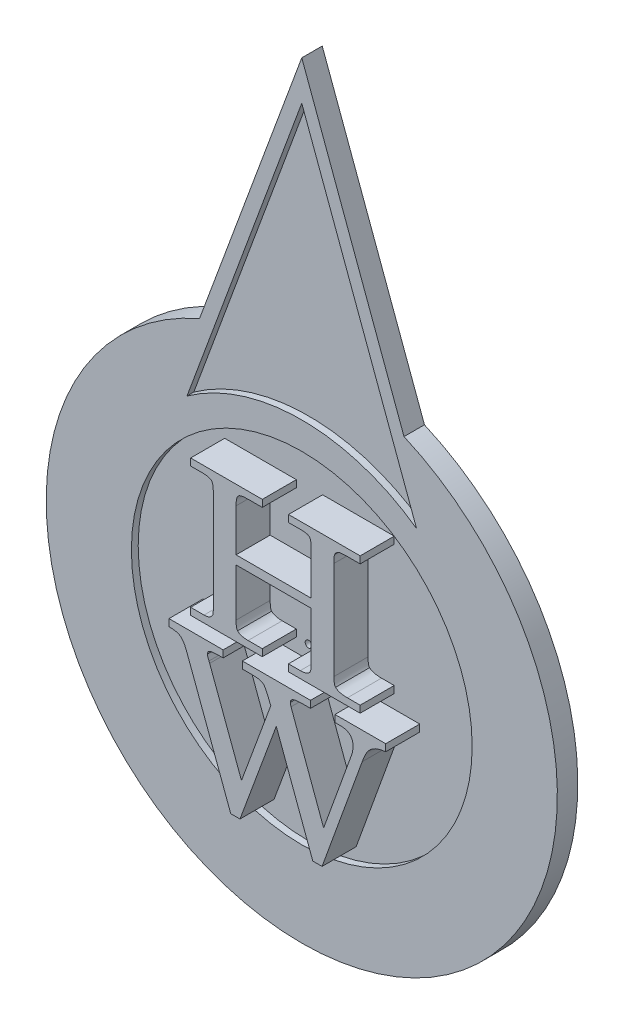
from build123d import *

# Parameters (mm, degrees)
BOSS_EXTRUDE1_DEPTH   = 3
SKETCH2_R             = 25
CUT_EXTRUDE1_DEPTH    = 1
SKETCH3_R             = 0.5
CUT_EXTRUDE2_DEPTH    = 3
CUT_EXTRUDE3_DEPTH    = 1
BOSS_EXTRUDE2_DEPTH   = 5
BOSS_EXTRUDE2_2_DEPTH = 5


with BuildPart() as part:
    # Sketch1 → Boss-Extrude1 (new body)
    with BuildSketch(Plane.XY):
        with BuildLine():
            Line((0, 75), (15, 34.369317712))
            ThreePointArc((15, 34.369317712), (0, -37.5), (-15, 34.369317712))
            Line((-15, 34.369317712), (0, 75))
        make_face()
    extrude(amount=BOSS_EXTRUDE1_DEPTH)

    # Sketch2 → Cut-Extrude1 (cut)
    with BuildSketch(Plane.XY.offset(3)):
        Circle(SKETCH2_R)
    extrude(amount=-CUT_EXTRUDE1_DEPTH, mode=Mode.SUBTRACT)

    # Sketch3 → Cut-Extrude2 (cut, through all)
    with BuildSketch(Plane.XY.offset(2)):
        Circle(SKETCH3_R)
    extrude(amount=-CUT_EXTRUDE2_DEPTH, mode=Mode.SUBTRACT)

    # Sketch4 → Cut-Extrude3 (cut)
    with BuildSketch(Plane.XY.offset(3)):
        with BuildLine():
            Line((16.840424663, 23.609322252), (0, 69.225185189))
            Line((0, 69.225185189), (-16.840424663, 23.609322252))
            ThreePointArc((-16.840424663, 23.609322252), (0, 29), (16.840424663, 23.609322252))
        make_face()
    extrude(amount=-CUT_EXTRUDE3_DEPTH, mode=Mode.SUBTRACT)


with BuildPart() as body_2:
    # Sketch5 → Boss-Extrude2 (new body)
    with BuildSketch(Plane.XY.offset(2)):
        with BuildLine():
            Line((-12.307692308, 20), (-1.794871795, 20))
            Line((-1.794871795, 20), (-1.794871795, 18.974358974))
            Line((-1.794871795, 18.974358974), (-3.878205128, 18.974358974))
            add(Edge.make_bspline(
                [(-3.878205128, 18.974358974), (-4.045156685, 18.970238719), (-4.348009251, 18.962764516), (-4.75953362, 18.918280987), (-5.074389701, 18.825957021), (-5.322099839, 18.693709511), (-5.475784154, 18.460687387), (-5.574066192, 18.146925306), (-5.633474469, 17.733149921), (-5.638341942, 17.422745299), (-5.641025641, 17.251602564)],
                knots=[0, 0, 0, 0, 0.000501202, 0.000909187, 0.001236146, 0.001484188, 0.001731029, 0.002049053, 0.002466663, 0.002979874, 0.002979874, 0.002979874, 0.002979874], degree=3))
            Line((-5.641025641, 17.251602564), (-5.641025641, 11.025641026))
            Line((-5.641025641, 11.025641026), (5.384615385, 11.025641026))
            Line((5.384615385, 11.025641026), (5.384615385, 17.251602564))
            add(Edge.make_bspline(
                [(5.384615385, 17.251602564), (5.383740839, 17.345077966), (5.38207839, 17.522767966), (5.372601025, 17.775774388), (5.345529534, 17.999673297), (5.322373184, 18.196376391), (5.279476869, 18.362860867), (5.236415565, 18.504296733), (5.173075514, 18.613578951), (5.084965049, 18.737881846), (4.896619502, 18.841281892), (4.607469436, 18.919925385), (4.225496381, 18.968656993), (3.939741887, 18.97233133), (3.782051282, 18.974358974)],
                knots=[0, 0, 0, 0, 0.000280477, 0.000533167, 0.00075881, 0.000957117, 0.001126196, 0.001274433, 0.001398178, 0.001503951, 0.001727342, 0.002020139, 0.002404295, 0.002877323, 0.002877323, 0.002877323, 0.002877323], degree=3))
            Line((3.782051282, 18.974358974), (2.051282051, 18.974358974))
            Line((2.051282051, 18.974358974), (2.051282051, 20))
            Line((2.051282051, 20), (12.564102564, 20))
            Line((12.564102564, 20), (12.564102564, 18.974358974))
            Line((12.564102564, 18.974358974), (10.456730769, 18.974358974))
            add(Edge.make_bspline(
                [(10.456730769, 18.974358974), (10.33515654, 18.973412428), (10.111642638, 18.971672205), (9.804429896, 18.945190942), (9.555917373, 18.89911702), (9.354816273, 18.836103073), (9.195676394, 18.740158358), (9.051486735, 18.628075987), (8.928149378, 18.481720833), (8.860689946, 18.370363816), (8.826121795, 18.313301282)],
                knots=[0, 0, 0, 0, 0.000364671, 0.000670447, 0.000923455, 0.001122368, 0.001298285, 0.00147786, 0.001668196, 0.001868236, 0.001868236, 0.001868236, 0.001868236], degree=3))
            add(Edge.make_bspline(
                [(8.826121795, 18.313301282), (8.808341001, 18.260272466), (8.76352112, 18.126603227), (8.742750032, 17.868690487), (8.721346843, 17.521873823), (8.719165775, 17.258399472), (8.717948718, 17.111378205)],
                knots=[0, 0, 0, 0, 0.000167313, 0.000421743, 0.000770876, 0.001211654, 0.001211654, 0.001211654, 0.001211654], degree=3))
            Line((8.717948718, 17.111378205), (8.717948718, 2.740384615))
            add(Edge.make_bspline(
                [(8.717948718, 2.740384615), (8.720199802, 2.583711901), (8.724213445, 2.304367259), (8.768525981, 1.940093321), (8.823772727, 1.66299249), (8.916083263, 1.538114394), (8.954326923, 1.486378205)],
                knots=[0, 0, 0, 0, 0.000469024, 0.000836261, 0.001106479, 0.001297614, 0.001297614, 0.001297614, 0.001297614], degree=3))
            add(Edge.make_bspline(
                [(8.954326923, 1.486378205), (9.047471267, 1.414271371), (9.249560154, 1.257826122), (9.652311829, 1.124236043), (10.14146426, 1.036373311), (10.501559145, 1.029418154), (10.697115385, 1.025641026)],
                knots=[0, 0, 0, 0, 0.000351196, 0.000761965, 0.001254688, 0.001840296, 0.001840296, 0.001840296, 0.001840296], degree=3))
            Line((10.697115385, 1.025641026), (12.564102564, 1.025641026))
            Line((12.564102564, 1.025641026), (12.564102564, 0))
            Line((12.564102564, 0), (2.051282051, 0))
            Line((2.051282051, 0), (2.051282051, 1.025641026))
            Line((2.051282051, 1.025641026), (3.782051282, 1.025641026))
            add(Edge.make_bspline(
                [(3.782051282, 1.025641026), (3.940285465, 1.029508782), (4.231662998, 1.036630994), (4.628207098, 1.124180298), (4.953900622, 1.265674046), (5.105185316, 1.421268776), (5.176282051, 1.494391026)],
                knots=[0, 0, 0, 0, 0.000473588, 0.000872079, 0.00121434, 0.001517798, 0.001517798, 0.001517798, 0.001517798], degree=3))
            add(Edge.make_bspline(
                [(5.176282051, 1.494391026), (5.21014806, 1.553286538), (5.292785844, 1.696999799), (5.340001474, 1.992761249), (5.382148789, 2.380899594), (5.383732111, 2.675948598), (5.384615385, 2.840544872)],
                knots=[0, 0, 0, 0, 0.000202472, 0.000494061, 0.000884742, 0.001377677, 0.001377677, 0.001377677, 0.001377677], degree=3))
            Line((5.384615385, 2.840544872), (5.384615385, 9.743589744))
            Line((5.384615385, 9.743589744), (-5.641025641, 9.743589744))
            Line((-5.641025641, 9.743589744), (-5.641025641, 2.732371795))
            add(Edge.make_bspline(
                [(-5.641025641, 2.732371795), (-5.64086642, 2.574297411), (-5.640582216, 2.292140871), (-5.5917522, 1.926497106), (-5.546684606, 1.648721841), (-5.460197507, 1.522279267), (-5.424679487, 1.470352564)],
                knots=[0, 0, 0, 0, 0.000472909, 0.000844124, 0.001112314, 0.001299204, 0.001299204, 0.001299204, 0.001299204], degree=3))
            add(Edge.make_bspline(
                [(-5.424679487, 1.470352564), (-5.339762769, 1.399466975), (-5.158352352, 1.248031726), (-4.793999877, 1.123894566), (-4.363349765, 1.037091416), (-4.04845653, 1.029659301), (-3.878205128, 1.025641026)],
                knots=[0, 0, 0, 0, 0.000329331, 0.00070356, 0.001136494, 0.00164608, 0.00164608, 0.00164608, 0.00164608], degree=3))
            Line((-3.878205128, 1.025641026), (-1.794871795, 1.025641026))
            Line((-1.794871795, 1.025641026), (-1.794871795, 0))
            Line((-1.794871795, 0), (-12.307692308, 0))
            Line((-12.307692308, 0), (-12.307692308, 1.025641026))
            Line((-12.307692308, 1.025641026), (-10.340544872, 1.025641026))
            add(Edge.make_bspline(
                [(-10.340544872, 1.025641026), (-10.257659482, 1.028119935), (-10.10055982, 1.03281842), (-9.87801973, 1.062972582), (-9.68280393, 1.119987362), (-9.461071936, 1.218555004), (-9.22371466, 1.400263421), (-9.111017801, 1.601686958), (-9.054487179, 1.702724359)],
                knots=[0, 0, 0, 0, 0.000248688, 0.000471359, 0.00067168, 0.000856366, 0.001198627, 0.001543109, 0.001543109, 0.001543109, 0.001543109], degree=3))
            add(Edge.make_bspline(
                [(-9.054487179, 1.702724359), (-9.04113329, 1.753239501), (-9.007159584, 1.881755359), (-8.992361774, 2.126059721), (-8.973980309, 2.456906922), (-8.974223318, 2.708249352), (-8.974358974, 2.848557692)],
                knots=[0, 0, 0, 0, 0.000156455, 0.000398039, 0.000730957, 0.001151649, 0.001151649, 0.001151649, 0.001151649], degree=3))
            Line((-8.974358974, 2.848557692), (-8.974358974, 17.271634615))
            add(Edge.make_bspline(
                [(-8.974358974, 17.271634615), (-8.977558103, 17.441446451), (-8.983323756, 17.747491168), (-9.036564541, 18.155637185), (-9.118938981, 18.466204164), (-9.260964684, 18.69525516), (-9.486388134, 18.828437927), (-9.775806496, 18.917901281), (-10.152319519, 18.962940554), (-10.431296335, 18.970303832), (-10.584935897, 18.974358974)],
                knots=[0, 0, 0, 0, 0.000509208, 0.000917725, 0.001232017, 0.001468701, 0.00170317, 0.001998369, 0.002374588, 0.002835761, 0.002835761, 0.002835761, 0.002835761], degree=3))
            Line((-10.584935897, 18.974358974), (-12.307692308, 18.974358974))
            Line((-12.307692308, 18.974358974), (-12.307692308, 20))
        make_face()
    extrude(amount=BOSS_EXTRUDE2_DEPTH)


with BuildPart() as body_3:
    # Sketch5 → Boss-Extrude2 2 (new body)
    with BuildSketch(Plane.XY.offset(2)):
        with BuildLine():
            Line((-15.487179487, -2), (-7.538461538, -2))
            Line((-7.538461538, -2), (-7.538461538, -3.025641026))
            Line((-7.538461538, -3.025641026), (-8.051282051, -3.025641026))
            add(Edge.make_bspline(
                [(-8.051282051, -3.025641026), (-8.225006282, -3.025701802), (-8.538103979, -3.025811338), (-8.957809283, -3.060174293), (-9.279366236, -3.098845179), (-9.511866937, -3.169912441), (-9.669484251, -3.267764357), (-9.776841592, -3.386839947), (-9.84465574, -3.530703597), (-9.850947714, -3.636552949), (-9.854166667, -3.690705128)],
                knots=[0, 0, 0, 0, 0.000520895, 0.000938793, 0.001262891, 0.00149094, 0.001662094, 0.001812481, 0.001966663, 0.002128166, 0.002128166, 0.002128166, 0.002128166], degree=3))
            add(Edge.make_bspline(
                [(-9.854166667, -3.690705128), (-9.85001231, -3.736308631), (-9.840471868, -3.841036637), (-9.792194072, -4.014186829), (-9.715304484, -4.220903901), (-9.649446062, -4.368168916), (-9.613782051, -4.447916667)],
                knots=[0, 0, 0, 0, 0.000137157, 0.000314981, 0.000536785, 0.000798769, 0.000798769, 0.000798769, 0.000798769], degree=3))
            Line((-9.613782051, -4.447916667), (-9.517628205, -4.700320513))
            Line((-9.517628205, -4.700320513), (-4.846153846, -17.256410256))
            Line((-4.846153846, -17.256410256), (-0.551282051, -5.609775641))
            add(Edge.make_bspline(
                [(-0.551282051, -5.609775641), (-0.60816157, -5.457332841), (-0.716361384, -5.167346519), (-0.878331357, -4.758853174), (-1.037977061, -4.403557445), (-1.173220941, -4.091921197), (-1.310556861, -3.836951139), (-1.433519122, -3.628902246), (-1.548869991, -3.471949845), (-1.692299404, -3.315635605), (-1.932981048, -3.190185657), (-2.285956334, -3.088828829), (-2.737297286, -3.035169755), (-3.069889887, -3.029007685), (-3.251602564, -3.025641026)],
                knots=[0, 0, 0, 0, 0.000488141, 0.000928573, 0.001317876, 0.001656743, 0.001947091, 0.002186203, 0.002380916, 0.00253109, 0.002818325, 0.003178278, 0.003631002, 0.004176242, 0.004176242, 0.004176242, 0.004176242], degree=3))
            Line((-3.251602564, -3.025641026), (-4.717948718, -3.025641026))
            Line((-4.717948718, -3.025641026), (-4.717948718, -2))
            Line((-4.717948718, -2), (5.282051282, -2))
            Line((5.282051282, -2), (5.282051282, -3.025641026))
            Line((5.282051282, -3.025641026), (4.328525641, -3.025641026))
            add(Edge.make_bspline(
                [(4.328525641, -3.025641026), (4.138842705, -3.02787589), (3.795206411, -3.031924649), (3.333180586, -3.06085871), (2.977458709, -3.110830852), (2.718006112, -3.18846297), (2.539574543, -3.294897082), (2.416131121, -3.419380106), (2.337507686, -3.570653998), (2.329453603, -3.681764041), (2.325320513, -3.738782051)],
                knots=[0, 0, 0, 0, 0.000569037, 0.001030888, 0.001387886, 0.001645077, 0.001837468, 0.002004637, 0.002165892, 0.00233587, 0.00233587, 0.00233587, 0.00233587], degree=3))
            add(Edge.make_bspline(
                [(2.325320513, -3.738782051), (2.328987361, -3.829076056), (2.336173437, -4.006029021), (2.3934328, -4.17356284), (2.421474359, -4.255608974)],
                knots=[0, 0, 0, 0, 0.000269504, 0.000528158, 0.000528158, 0.000528158, 0.000528158], degree=3))
            Line((2.421474359, -4.255608974), (7.205128205, -17.256410256))
            Line((7.205128205, -17.256410256), (11.279647436, -6.010416667))
            add(Edge.make_bspline(
                [(11.279647436, -6.010416667), (11.316011197, -5.90273874), (11.387106757, -5.692215347), (11.46382282, -5.374906286), (11.509526113, -5.063567585), (11.5165556, -4.858049679), (11.520032051, -4.756410256)],
                knots=[0, 0, 0, 0, 0.000340828, 0.000666359, 0.000977985, 0.001282893, 0.001282893, 0.001282893, 0.001282893], degree=3))
            add(Edge.make_bspline(
                [(11.520032051, -4.756410256), (11.51392447, -4.617072396), (11.50244875, -4.355266275), (11.417063348, -3.989109624), (11.261523138, -3.682347931), (11.043017926, -3.434933699), (10.763212398, -3.245359644), (10.425063447, -3.115146155), (10.028796728, -3.041239163), (9.746857921, -3.031055521), (9.596955128, -3.025641026)],
                knots=[0, 0, 0, 0, 0.000417898, 0.0007852, 0.00111848, 0.001439218, 0.001764823, 0.002122675, 0.002518682, 0.002968275, 0.002968275, 0.002968275, 0.002968275], degree=3))
            Line((9.596955128, -3.025641026), (8.871794872, -3.025641026))
            Line((8.871794872, -3.025641026), (8.871794872, -2))
            Line((8.871794872, -2), (16.307692308, -2))
            Line((16.307692308, -2), (16.307692308, -3.025641026))
            add(Edge.make_bspline(
                [(16.307692308, -3.025641026), (16.151075854, -3.044628518), (15.853476206, -3.080708195), (15.434005532, -3.169079846), (15.064938368, -3.279525094), (14.741057448, -3.41336961), (14.4530559, -3.573006085), (14.190807596, -3.764122968), (13.945393451, -3.984772929), (13.714378393, -4.245666044), (13.488996006, -4.56465044), (13.285251253, -4.971566689), (13.059583377, -5.455816322), (12.931099612, -5.81678763), (12.862179487, -6.010416667)],
                knots=[0, 0, 0, 0, 0.000473113, 0.000899, 0.001284283, 0.001627293, 0.001948331, 0.002269694, 0.002598757, 0.002936462, 0.003313256, 0.003766689, 0.004299195, 0.004915349, 0.004915349, 0.004915349, 0.004915349], degree=3))
            Line((12.862179487, -6.010416667), (6.976762821, -22.256410256))
            Line((6.976762821, -22.256410256), (5.618589744, -22.256410256))
            Line((5.618589744, -22.256410256), (0.262019231, -7.805288462))
            Line((0.262019231, -7.805288462), (-5.06650641, -22.256410256))
            Line((-5.06650641, -22.256410256), (-6.420673077, -22.256410256))
            Line((-6.420673077, -22.256410256), (-12.955128205, -4.700320513))
            add(Edge.make_bspline(
                [(-12.955128205, -4.700320513), (-13.021237466, -4.542515559), (-13.144026305, -4.249414611), (-13.363420168, -3.86307262), (-13.598576434, -3.563171836), (-13.861668555, -3.342852073), (-14.172265335, -3.192186644), (-14.544169994, -3.092690551), (-14.991260878, -3.034900859), (-15.313377483, -3.028886271), (-15.487179487, -3.025641026)],
                knots=[0, 0, 0, 0, 0.000512961, 0.000952755, 0.001328803, 0.001650441, 0.001972951, 0.002355977, 0.00280076, 0.003321979, 0.003321979, 0.003321979, 0.003321979], degree=3))
            Line((-15.487179487, -3.025641026), (-15.487179487, -2))
        make_face()
    extrude(amount=BOSS_EXTRUDE2_2_DEPTH)


solid = Compound([part.part, body_2.part, body_3.part])
